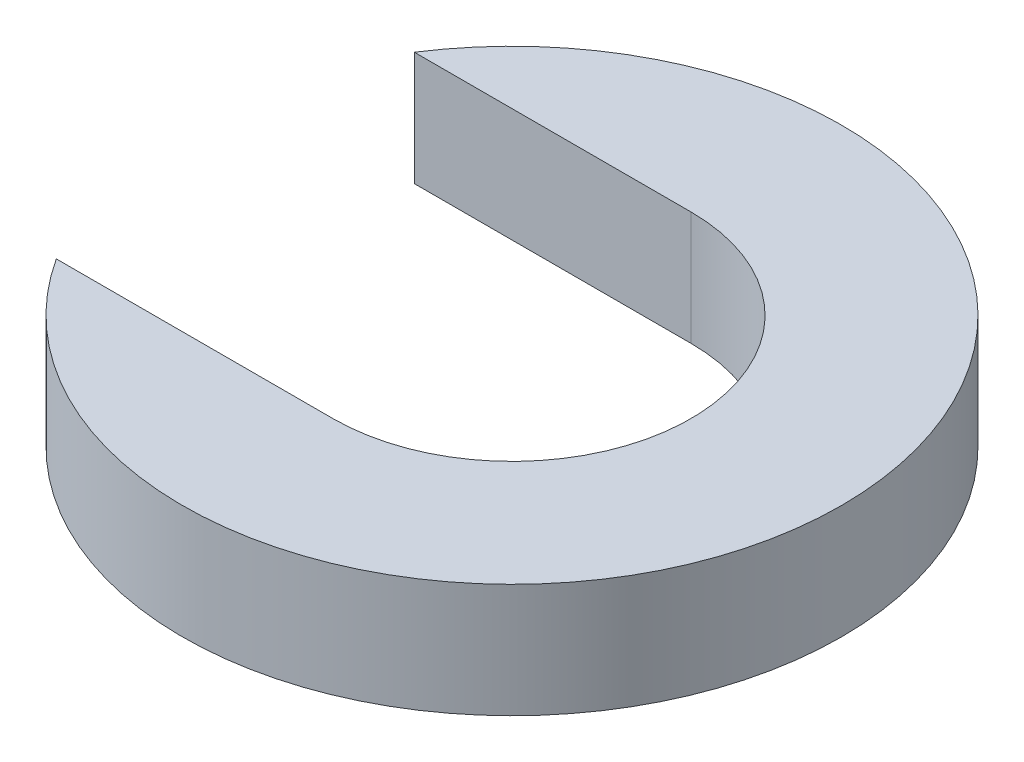
from build123d import *

# Parameters (mm, degrees)
BOSS_EXTRUDE1_DEPTH = 3.1496


with BuildPart() as part:
    # Sketch2 → Boss-Extrude1 (new body)
    with BuildSketch(Plane(origin=(0, 0, 0), x_dir=(1, 0, 0), z_dir=(0, 1, 0))):
        with BuildLine():
            Line((0, 4.953), (-7.656151576, 4.953))
            ThreePointArc((-7.656151576, 4.953), (9.1186, 0), (-7.656151576, -4.953))
            Line((-7.656151576, -4.953), (0, -4.953))
            ThreePointArc((0, -4.953), (4.953, 0), (0, 4.953))
        make_face()
    extrude(amount=BOSS_EXTRUDE1_DEPTH)


solid = part.part
